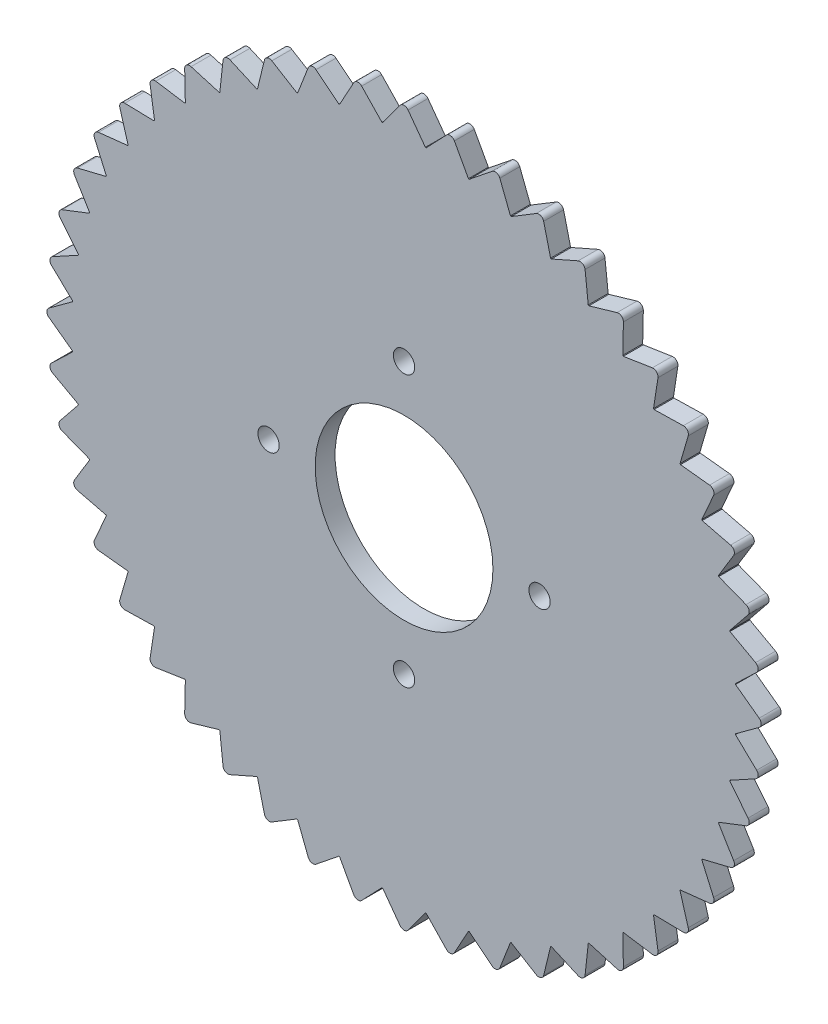
from build123d import *

# Parameters (mm, degrees)
CROQUIS1_R              = 46.7
CROQUIS1_R_2            = 12.5
CROQUIS1_R_3            = 1.5
SALIENTE_EXTRUIR1_DEPTH = 2.8
SALIENTE_EXTRUIR3_DEPTH = 2.8
REDONDEO1_R             = 0.7


with BuildPart() as part:
    # Croquis1 → Saliente-Extruir1 (new body)
    with BuildSketch(Plane.XY):
        Circle(CROQUIS1_R)
        Circle(CROQUIS1_R_2, mode=Mode.SUBTRACT)
        with Locations((0, 19.05)):
            Circle(CROQUIS1_R_3, mode=Mode.SUBTRACT)
        with Locations((19.05, 0)):
            Circle(CROQUIS1_R_3, mode=Mode.SUBTRACT)
        with Locations((0, -19.05)):
            Circle(CROQUIS1_R_3, mode=Mode.SUBTRACT)
        with Locations((-19.05, 0)):
            Circle(CROQUIS1_R_3, mode=Mode.SUBTRACT)
    extrude(amount=SALIENTE_EXTRUIR1_DEPTH)

    # Croquis2 → Saliente-Extruir3 (add)
    with BuildSketch(Plane.XY.offset(2.8)):
        with BuildLine():
            Line((3, 46.603540638), (0, 50.7))
            Line((0, 50.7), (-3, 46.603540638))
            ThreePointArc((-3, 46.603540638), (0, 46.7), (3, 46.603540638))
        make_face()
        with BuildLine():
            ThreePointArc((-9.057317288, 45.813262311), (-6.095573177, 46.300475026), (-3.108648119, 46.596419464))
            Line((-3.108648119, 46.596419464), (-6.617677946, 50.266254472))
            Line((-6.617677946, 50.266254472), (-9.057317288, 45.813262311))
        make_face()
        with BuildLine():
            ThreePointArc((-14.959661365, 44.239106363), (-12.086849406, 45.108736088), (-9.164106407, 45.792020634))
            Line((-9.164106407, 45.792020634), (-13.122125587, 48.972439393))
            Line((-13.122125587, 48.972439393), (-14.959661365, 44.239106363))
        make_face()
        with BuildLine():
            ThreePointArc((-20.606041489, 41.908007041), (-17.871316291, 43.145174168), (-15.062764294, 44.204107635))
            Line((-15.062764294, 44.204107635), (-19.402050021, 46.840692298))
            Line((-19.402050021, 46.840692298), (-20.606041489, 41.908007041))
        make_face()
        with BuildLine():
            ThreePointArc((-25.89984653, 38.859850099), (-23.35, 40.443386357), (-20.703694108, 41.859850099))
            Line((-20.703694108, 41.859850099), (-25.35, 43.907487972))
            Line((-25.35, 43.907487972), (-25.89984653, 38.859850099))
        make_face()
        with BuildLine():
            ThreePointArc((-30.750498017, 35.146790348), (-28.429158735, 37.049600992), (-25.990377975, 38.799358922))
            Line((-25.990377975, 38.799358922), (-30.864204451, 40.223014353))
            Line((-30.864204451, 40.223014353), (-30.750498017, 35.146790348))
        make_face()
        with BuildLine():
            ThreePointArc((-35.074999956, 30.832359269), (-33.021886681, 33.021886681), (-30.832359269, 35.074999956))
            Line((-30.832359269, 35.074999956), (-35.850313806, 35.850313806))
            Line((-35.850313806, 35.850313806), (-35.074999956, 30.832359269))
        make_face()
        with BuildLine():
            ThreePointArc((-38.799358922, 25.990377975), (-37.049600992, 28.429158735), (-35.146790348, 30.750498017))
            Line((-35.146790348, 30.750498017), (-40.223014353, 30.864204451))
            Line((-40.223014353, 30.864204451), (-38.799358922, 25.990377975))
        make_face()
        with BuildLine():
            ThreePointArc((-41.859850099, 20.703694108), (-40.443386357, 23.35), (-38.859850099, 25.89984653))
            Line((-38.859850099, 25.89984653), (-43.907487972, 25.35))
            Line((-43.907487972, 25.35), (-41.859850099, 20.703694108))
        make_face()
        with BuildLine():
            ThreePointArc((-44.204107635, 15.062764294), (-43.145174168, 17.871316291), (-41.908007041, 20.606041489))
            Line((-41.908007041, 20.606041489), (-46.840692298, 19.402050021))
            Line((-46.840692298, 19.402050021), (-44.204107635, 15.062764294))
        make_face()
        with BuildLine():
            ThreePointArc((-45.792020634, 9.164106407), (-45.108736088, 12.086849406), (-44.239106363, 14.959661365))
            Line((-44.239106363, 14.959661365), (-48.972439393, 13.122125587))
            Line((-48.972439393, 13.122125587), (-45.792020634, 9.164106407))
        make_face()
        with BuildLine():
            ThreePointArc((-46.596419464, 3.108648119), (-46.300475026, 6.095573177), (-45.813262311, 9.057317288))
            Line((-45.813262311, 9.057317288), (-50.266254472, 6.617677946))
            Line((-50.266254472, 6.617677946), (-46.596419464, 3.108648119))
        make_face()
        with BuildLine():
            ThreePointArc((-46.603540638, -3), (-46.7, 0), (-46.603540638, 3))
            Line((-46.603540638, 3), (-50.7, 0))
            Line((-50.7, 0), (-46.603540638, -3))
        make_face()
        with BuildLine():
            ThreePointArc((-45.813262311, -9.057317288), (-46.300475026, -6.095573177), (-46.596419464, -3.108648119))
            Line((-46.596419464, -3.108648119), (-50.266254472, -6.617677946))
            Line((-50.266254472, -6.617677946), (-45.813262311, -9.057317288))
        make_face()
        with BuildLine():
            ThreePointArc((-44.239106363, -14.959661365), (-45.108736088, -12.086849406), (-45.792020634, -9.164106407))
            Line((-45.792020634, -9.164106407), (-48.972439393, -13.122125587))
            Line((-48.972439393, -13.122125587), (-44.239106363, -14.959661365))
        make_face()
        with BuildLine():
            ThreePointArc((-41.908007041, -20.606041489), (-43.145174168, -17.871316291), (-44.204107635, -15.062764294))
            Line((-44.204107635, -15.062764294), (-46.840692298, -19.402050021))
            Line((-46.840692298, -19.402050021), (-41.908007041, -20.606041489))
        make_face()
        with BuildLine():
            ThreePointArc((-38.859850099, -25.89984653), (-40.443386357, -23.35), (-41.859850099, -20.703694108))
            Line((-41.859850099, -20.703694108), (-43.907487972, -25.35))
            Line((-43.907487972, -25.35), (-38.859850099, -25.89984653))
        make_face()
        with BuildLine():
            ThreePointArc((-35.146790348, -30.750498017), (-37.049600992, -28.429158735), (-38.799358922, -25.990377975))
            Line((-38.799358922, -25.990377975), (-40.223014353, -30.864204451))
            Line((-40.223014353, -30.864204451), (-35.146790348, -30.750498017))
        make_face()
        with BuildLine():
            ThreePointArc((-30.832359269, -35.074999956), (-33.021886681, -33.021886681), (-35.074999956, -30.832359269))
            Line((-35.074999956, -30.832359269), (-35.850313806, -35.850313806))
            Line((-35.850313806, -35.850313806), (-30.832359269, -35.074999956))
        make_face()
        with BuildLine():
            ThreePointArc((-25.990377975, -38.799358922), (-28.429158735, -37.049600992), (-30.750498017, -35.146790348))
            Line((-30.750498017, -35.146790348), (-30.864204451, -40.223014353))
            Line((-30.864204451, -40.223014353), (-25.990377975, -38.799358922))
        make_face()
        with BuildLine():
            ThreePointArc((-20.703694108, -41.859850099), (-23.35, -40.443386357), (-25.89984653, -38.859850099))
            Line((-25.89984653, -38.859850099), (-25.35, -43.907487972))
            Line((-25.35, -43.907487972), (-20.703694108, -41.859850099))
        make_face()
        with BuildLine():
            ThreePointArc((-15.062764294, -44.204107635), (-17.871316291, -43.145174168), (-20.606041489, -41.908007041))
            Line((-20.606041489, -41.908007041), (-19.402050021, -46.840692298))
            Line((-19.402050021, -46.840692298), (-15.062764294, -44.204107635))
        make_face()
        with BuildLine():
            ThreePointArc((-9.164106407, -45.792020634), (-12.086849406, -45.108736088), (-14.959661365, -44.239106363))
            Line((-14.959661365, -44.239106363), (-13.122125587, -48.972439393))
            Line((-13.122125587, -48.972439393), (-9.164106407, -45.792020634))
        make_face()
        with BuildLine():
            ThreePointArc((-3.108648119, -46.596419464), (-6.095573177, -46.300475026), (-9.057317288, -45.813262311))
            Line((-9.057317288, -45.813262311), (-6.617677946, -50.266254472))
            Line((-6.617677946, -50.266254472), (-3.108648119, -46.596419464))
        make_face()
        with BuildLine():
            ThreePointArc((3, -46.603540638), (0, -46.7), (-3, -46.603540638))
            Line((-3, -46.603540638), (0, -50.7))
            Line((0, -50.7), (3, -46.603540638))
        make_face()
        with BuildLine():
            Line((6.617677946, -50.266254472), (9.057317288, -45.813262311))
            ThreePointArc((9.057317288, -45.813262311), (6.095573177, -46.300475026), (3.108648119, -46.596419464))
            Line((3.108648119, -46.596419464), (6.617677946, -50.266254472))
        make_face()
        with BuildLine():
            Line((13.122125587, -48.972439393), (14.959661365, -44.239106363))
            ThreePointArc((14.959661365, -44.239106363), (12.086849406, -45.108736088), (9.164106407, -45.792020634))
            Line((9.164106407, -45.792020634), (13.122125587, -48.972439393))
        make_face()
        with BuildLine():
            Line((19.402050021, -46.840692298), (20.606041489, -41.908007041))
            ThreePointArc((20.606041489, -41.908007041), (17.871316291, -43.145174168), (15.062764294, -44.204107635))
            Line((15.062764294, -44.204107635), (19.402050021, -46.840692298))
        make_face()
        with BuildLine():
            Line((25.35, -43.907487972), (25.89984653, -38.859850099))
            ThreePointArc((25.89984653, -38.859850099), (23.35, -40.443386357), (20.703694108, -41.859850099))
            Line((20.703694108, -41.859850099), (25.35, -43.907487972))
        make_face()
        with BuildLine():
            Line((30.864204451, -40.223014353), (30.750498017, -35.146790348))
            ThreePointArc((30.750498017, -35.146790348), (28.429158735, -37.049600992), (25.990377975, -38.799358922))
            Line((25.990377975, -38.799358922), (30.864204451, -40.223014353))
        make_face()
        with BuildLine():
            Line((35.850313806, -35.850313806), (35.074999956, -30.832359269))
            ThreePointArc((35.074999956, -30.832359269), (33.021886681, -33.021886681), (30.832359269, -35.074999956))
            Line((30.832359269, -35.074999956), (35.850313806, -35.850313806))
        make_face()
        with BuildLine():
            Line((40.223014353, -30.864204451), (38.799358922, -25.990377975))
            ThreePointArc((38.799358922, -25.990377975), (37.049600992, -28.429158735), (35.146790348, -30.750498017))
            Line((35.146790348, -30.750498017), (40.223014353, -30.864204451))
        make_face()
        with BuildLine():
            Line((43.907487972, -25.35), (41.859850099, -20.703694108))
            ThreePointArc((41.859850099, -20.703694108), (40.443386357, -23.35), (38.859850099, -25.89984653))
            Line((38.859850099, -25.89984653), (43.907487972, -25.35))
        make_face()
        with BuildLine():
            Line((46.840692298, -19.402050021), (44.204107635, -15.062764294))
            ThreePointArc((44.204107635, -15.062764294), (43.145174168, -17.871316291), (41.908007041, -20.606041489))
            Line((41.908007041, -20.606041489), (46.840692298, -19.402050021))
        make_face()
        with BuildLine():
            Line((48.972439393, -13.122125587), (45.792020634, -9.164106407))
            ThreePointArc((45.792020634, -9.164106407), (45.108736088, -12.086849406), (44.239106363, -14.959661365))
            Line((44.239106363, -14.959661365), (48.972439393, -13.122125587))
        make_face()
        with BuildLine():
            Line((50.266254472, -6.617677946), (46.596419464, -3.108648119))
            ThreePointArc((46.596419464, -3.108648119), (46.300475026, -6.095573177), (45.813262311, -9.057317288))
            Line((45.813262311, -9.057317288), (50.266254472, -6.617677946))
        make_face()
        with BuildLine():
            Line((50.7, 0), (46.603540638, 3))
            ThreePointArc((46.603540638, 3), (46.67587893, 1.500775167), (46.7, 0))
            ThreePointArc((46.7, 0), (46.67587893, -1.500775167), (46.603540638, -3))
            Line((46.603540638, -3), (50.7, 0))
        make_face()
        with BuildLine():
            Line((50.266254472, 6.617677946), (45.813262311, 9.057317288))
            ThreePointArc((45.813262311, 9.057317288), (46.300475026, 6.095573177), (46.596419464, 3.108648119))
            Line((46.596419464, 3.108648119), (50.266254472, 6.617677946))
        make_face()
        with BuildLine():
            Line((48.972439393, 13.122125587), (44.239106363, 14.959661365))
            ThreePointArc((44.239106363, 14.959661365), (45.108736088, 12.086849406), (45.792020634, 9.164106407))
            Line((45.792020634, 9.164106407), (48.972439393, 13.122125587))
        make_face()
        with BuildLine():
            Line((46.840692298, 19.402050021), (41.908007041, 20.606041489))
            ThreePointArc((41.908007041, 20.606041489), (43.145174168, 17.871316291), (44.204107635, 15.062764294))
            Line((44.204107635, 15.062764294), (46.840692298, 19.402050021))
        make_face()
        with BuildLine():
            Line((43.907487972, 25.35), (38.859850099, 25.89984653))
            ThreePointArc((38.859850099, 25.89984653), (40.443386357, 23.35), (41.859850099, 20.703694108))
            Line((41.859850099, 20.703694108), (43.907487972, 25.35))
        make_face()
        with BuildLine():
            Line((40.223014353, 30.864204451), (35.146790348, 30.750498017))
            ThreePointArc((35.146790348, 30.750498017), (37.049600992, 28.429158735), (38.799358922, 25.990377975))
            Line((38.799358922, 25.990377975), (40.223014353, 30.864204451))
        make_face()
        with BuildLine():
            Line((35.850313806, 35.850313806), (30.832359269, 35.074999956))
            ThreePointArc((30.832359269, 35.074999956), (33.021886681, 33.021886681), (35.074999956, 30.832359269))
            Line((35.074999956, 30.832359269), (35.850313806, 35.850313806))
        make_face()
        with BuildLine():
            Line((30.864204451, 40.223014353), (25.990377975, 38.799358922))
            ThreePointArc((25.990377975, 38.799358922), (28.429158735, 37.049600992), (30.750498017, 35.146790348))
            Line((30.750498017, 35.146790348), (30.864204451, 40.223014353))
        make_face()
        with BuildLine():
            Line((25.35, 43.907487972), (20.703694108, 41.859850099))
            ThreePointArc((20.703694108, 41.859850099), (23.35, 40.443386357), (25.89984653, 38.859850099))
            Line((25.89984653, 38.859850099), (25.35, 43.907487972))
        make_face()
        with BuildLine():
            Line((19.402050021, 46.840692298), (15.062764294, 44.204107635))
            ThreePointArc((15.062764294, 44.204107635), (17.871316291, 43.145174168), (20.606041489, 41.908007041))
            Line((20.606041489, 41.908007041), (19.402050021, 46.840692298))
        make_face()
        with BuildLine():
            Line((13.122125587, 48.972439393), (9.164106407, 45.792020634))
            ThreePointArc((9.164106407, 45.792020634), (12.086849406, 45.108736088), (14.959661365, 44.239106363))
            Line((14.959661365, 44.239106363), (13.122125587, 48.972439393))
        make_face()
        with BuildLine():
            Line((6.617677946, 50.266254472), (3.108648119, 46.596419464))
            ThreePointArc((3.108648119, 46.596419464), (6.095573177, 46.300475026), (9.057317288, 45.813262311))
            Line((9.057317288, 45.813262311), (6.617677946, 50.266254472))
        make_face()
    extrude(amount=-SALIENTE_EXTRUIR3_DEPTH)

    # Redondeo1
    redondeo1_edges = [part.edges().sort_by_distance(p)[0] for p in [
        (-43.907487972, 25.35, 1.4),
        (-46.840692298, 19.402050021, 1.4),
        (-48.972439393, 13.122125587, 1.4),
        (-50.266254472, 6.617677946, 1.4),
        (-50.7, 0, 1.4),
        (-50.266254472, -6.617677946, 1.4),
        (-48.972439393, -13.122125587, 1.4),
        (-46.840692298, -19.402050021, 1.4),
        (-43.907487972, -25.35, 1.4),
        (-40.223014353, -30.864204451, 1.4),
        (-35.850313806, -35.850313806, 1.4),
        (-30.864204451, -40.223014353, 1.4),
        (-25.35, -43.907487972, 1.4),
        (-19.402050021, -46.840692298, 1.4),
        (-13.122125587, -48.972439393, 1.4),
        (-6.617677946, -50.266254472, 1.4),
        (0, -50.7, 1.4),
        (6.617677946, -50.266254472, 1.4),
        (13.122125587, -48.972439393, 1.4),
        (0, 50.7, 1.4),
        (19.402050021, -46.840692298, 1.4),
        (25.35, -43.907487972, 1.4),
        (30.864204451, -40.223014353, 1.4),
        (35.850313806, -35.850313806, 1.4),
        (40.223014353, -30.864204451, 1.4),
        (43.907487972, -25.35, 1.4),
        (46.840692298, -19.402050021, 1.4),
        (48.972439393, -13.122125587, 1.4),
        (50.266254472, -6.617677946, 1.4),
        (50.7, 0, 1.4),
        (-6.617677946, 50.266254472, 1.4),
        (50.266254472, 6.617677946, 1.4),
        (48.972439393, 13.122125587, 1.4),
        (46.840692298, 19.402050021, 1.4),
        (43.907487972, 25.35, 1.4),
        (40.223014353, 30.864204451, 1.4),
        (35.850313806, 35.850313806, 1.4),
        (30.864204451, 40.223014353, 1.4),
        (25.35, 43.907487972, 1.4),
        (19.402050021, 46.840692298, 1.4),
        (13.122125587, 48.972439393, 1.4),
        (-13.122125587, 48.972439393, 1.4),
        (6.617677946, 50.266254472, 1.4),
        (-19.402050021, 46.840692298, 1.4),
        (-25.35, 43.907487972, 1.4),
        (-30.864204451, 40.223014353, 1.4),
        (-35.850313806, 35.850313806, 1.4),
        (-40.223014353, 30.864204451, 1.4),
    ]]
    fillet(redondeo1_edges, radius=REDONDEO1_R)


solid = part.part
